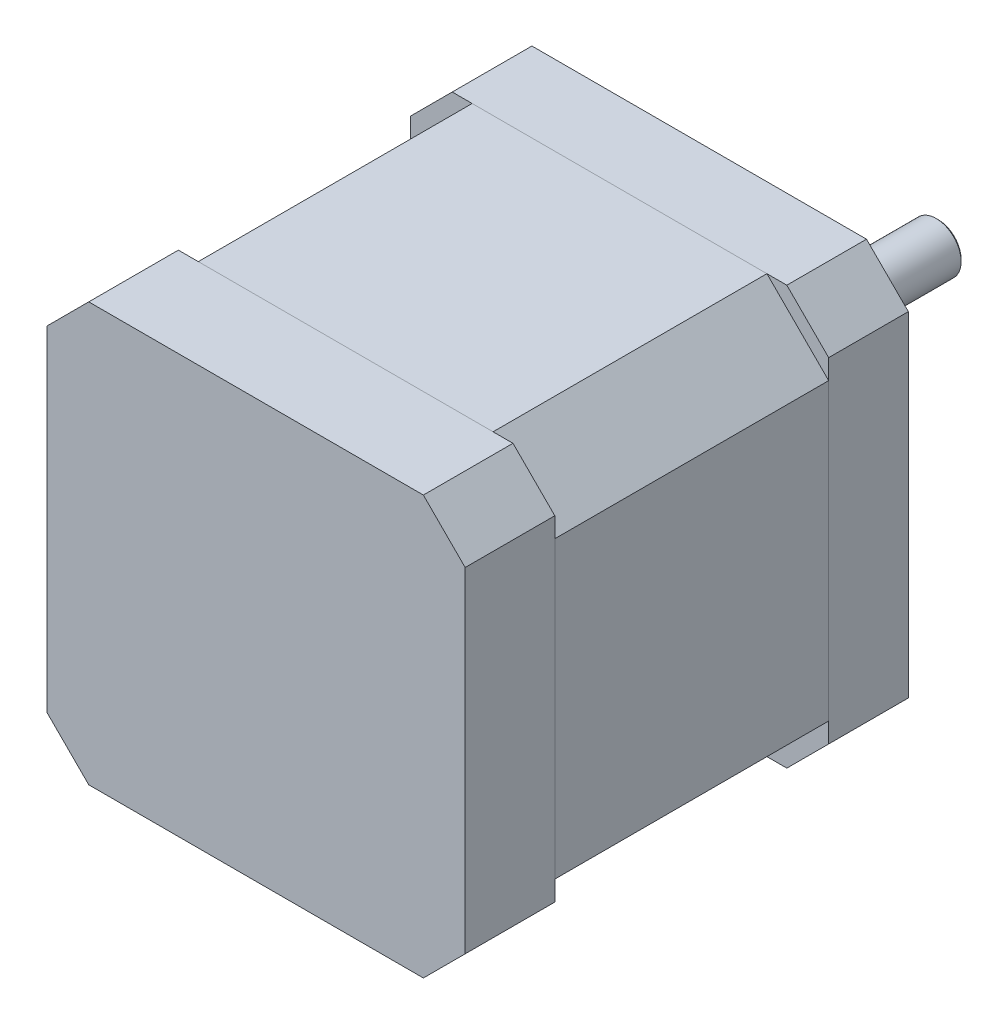
from build123d import *

# Parameters (mm, degrees)
ESQUISSE1_W             = 42
ESQUISSE1_H             = 42
BOSS_EXTRU_1_DEPTH      = 8
CHANFREIN1_SIZE         = 4.2
BOSS_EXTRU_2_DEPTH      = 27.5
ESQUISSE4_W             = 42
ESQUISSE4_H             = 42
BOSS_EXTRU_3_DEPTH      = 9
CHANFREIN3_SIZE         = 4.2
ESQUISSE5_R             = 11
BOSS_EXTRU_4_DEPTH      = 2
ESQUISSE6_R             = 4.5
ENL_V_MAT_EXTRU_1_DEPTH = 3
ESQUISSE7_R             = 2.5
BOSS_EXTRU_5_DEPTH      = 25
CHANFREIN4_SIZE         = 0.2
ESQUISSE8_R             = 1.5
ENL_V_MAT_EXTRU_2_DEPTH = 5
CHANFREIN5_SIZE         = 0.2
ESQUISSE9_W             = 7
ESQUISSE9_H             = 8
ENL_V_MAT_EXTRU_3_DEPTH = 2


with BuildPart() as part:
    # Esquisse1 → Boss.-Extru.1 (new body)
    with BuildSketch(Plane.XY):
        Rectangle(ESQUISSE1_W, ESQUISSE1_H)
    extrude(amount=BOSS_EXTRU_1_DEPTH)

    # Chanfrein1
    chanfrein1_edges = [part.edges().sort_by_distance(p)[0] for p in [
        (21, -21, 4),
        (-21, -21, 4),
        (-21, 21, 4),
        (21, 21, 4),
    ]]
    chamfer(chanfrein1_edges, length=CHANFREIN1_SIZE)

    # Esquisse5 → Boss.-Extru.4 (add)
    with BuildSketch(Plane(origin=(0, 0, 0), x_dir=(-1, 0, 0), z_dir=(0, 0, -1))):
        Circle(ESQUISSE5_R)
    extrude(amount=BOSS_EXTRU_4_DEPTH)

    # Esquisse6 → Enlèv. mat.-Extru.1 (cut)
    with BuildSketch(Plane(origin=(0, 0, -2), x_dir=(-1, 0, 0), z_dir=(0, 0, -1))):
        Circle(ESQUISSE6_R)
    extrude(amount=-ENL_V_MAT_EXTRU_1_DEPTH, mode=Mode.SUBTRACT)

    # Esquisse7 → Boss.-Extru.5 (add)
    with BuildSketch(Plane(origin=(0, 0, 1), x_dir=(-1, 0, 0), z_dir=(0, 0, -1))):
        Circle(ESQUISSE7_R)
    extrude(amount=BOSS_EXTRU_5_DEPTH)

    # Chanfrein4
    chanfrein4_edges = [part.edges().sort_by_distance(p)[0] for p in [
        (2.5, 0, -24),
    ]]
    chamfer(chanfrein4_edges, length=CHANFREIN4_SIZE)

    # Esquisse8 → Enlèv. mat.-Extru.2 (cut)
    with BuildSketch(Plane(origin=(0, 0, 0), x_dir=(-1, 0, 0), z_dir=(0, 0, -1))):
        with Locations((-15.5, 15.5)):
            Circle(ESQUISSE8_R)
        with Locations((15.5, 15.5)):
            Circle(ESQUISSE8_R)
        with Locations((15.5, -15.5)):
            Circle(ESQUISSE8_R)
        with Locations((-15.5, -15.5)):
            Circle(ESQUISSE8_R)
    extrude(amount=-ENL_V_MAT_EXTRU_2_DEPTH, mode=Mode.SUBTRACT)

    # Chanfrein5
    chanfrein5_edges = [part.edges().sort_by_distance(p)[0] for p in [
        (17, 15.5, 0),
        (-14, 15.5, 0),
        (-14, -15.5, 0),
        (17, -15.5, 0),
    ]]
    chamfer(chanfrein5_edges, length=CHANFREIN5_SIZE)


with BuildPart() as body_2:
    # Esquisse3 → Boss.-Extru.2 (new body)
    with BuildSketch(Plane.XY.offset(8)):
        Polygon((-21, 14.8), (-14.8, 21), (14.8, 21), (21, 14.8), (21, -14.8), (14.8, -21), (-14.8, -21), (-21, -14.8), align=None)
    extrude(amount=BOSS_EXTRU_2_DEPTH)


with BuildPart() as body_3:
    # Esquisse4 → Boss.-Extru.3 (new body)
    with BuildSketch(Plane.XY.offset(35.5)):
        Rectangle(ESQUISSE4_W, ESQUISSE4_H)
    extrude(amount=BOSS_EXTRU_3_DEPTH)

    # Chanfrein3
    chanfrein3_edges = [body_3.edges().sort_by_distance(p)[0] for p in [
        (21, -21, 40),
        (-21, -21, 40),
        (-21, 21, 40),
        (21, 21, 40),
    ]]
    chamfer(chanfrein3_edges, length=CHANFREIN3_SIZE)

    # Esquisse9 → Enlèv. mat.-Extru.3 (cut)
    with BuildSketch(Plane.ZY.offset(21)):
        with Locations((39, 0)):
            Rectangle(ESQUISSE9_W, ESQUISSE9_H)
    extrude(amount=-ENL_V_MAT_EXTRU_3_DEPTH, mode=Mode.SUBTRACT)


solid = Compound([part.part, body_2.part, body_3.part])
